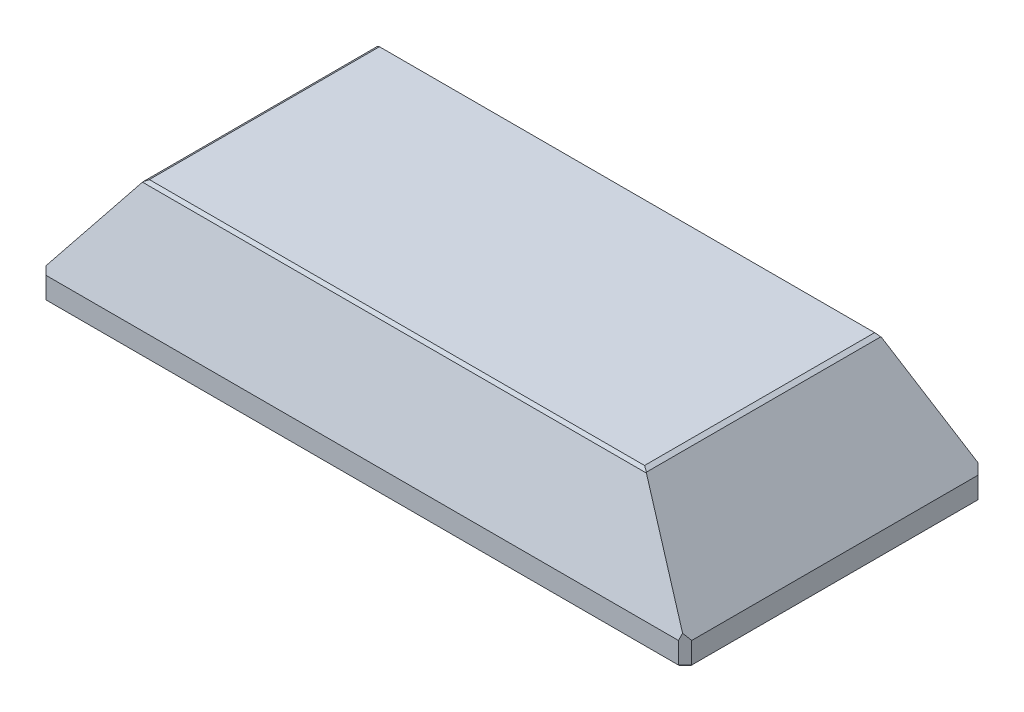
from build123d import *
from OCP.BRepFilletAPI import BRepFilletAPI_MakeChamfer

# Parameters (mm, degrees)
SKETCH1_W                       = 194
SKETCH1_H                       = 90
BOSS_EXTRUDE1_DEPTH             = 7
SKETCH3_W                       = 194
SKETCH3_H                       = 90
SKETCH2_W                       = 150
SKETCH2_H                       = 70
CHAMFER1_SIZE                   = 2
SKETCH4_R                       = 2.15
CUT_EXTRUDE1_DEPTH              = 7
SKETCH5_W                       = 150
SKETCH5_H                       = 60
CUT_EXTRUDE2_DEPTH              = 36
SKETCH6_W                       = 150
SKETCH6_H                       = 64
CUT_EXTRUDE3_DEPTH              = 32
SKETCH7_W                       = 6
SKETCH7_H                       = 64
CUT_EXTRUDE4_DEPTH              = 4
SKETCH8_R                       = 2.05
CUT_EXTRUDE5_DEPTH              = 6
CHAMFER2_SIZE                   = 1
CHAMFER2_SIZE2                  = 0.615681714
CHAMFER2_SIZE2_2                = 0.436631997
CHAMFER3_SIZE                   = 0.6
SKIZZE1_W                       = 54.050484576
SKIZZE1_H                       = 12.5
SKIZZE1_W_2                     = 40
SKIZZE1_H_2                     = 21.453027382
AUFSATZ_LINEAR_AUSTRAGEN1_DEPTH = 10
SKIZZE3_W                       = 47.974757712
SKIZZE3_H                       = 1
SCHNITT_LINEAR_AUSTRAGEN2_DEPTH = 4
SKETCH9_W                       = 150
SKETCH9_H                       = 64
CUT_EXTRUDE6_DEPTH              = 32
CHAMFER4_SIZE                   = 0.4


with BuildPart() as part:
    # Sketch1 → Boss-Extrude1 (new body)
    with BuildSketch(Plane(origin=(0, 0, 0), x_dir=(1, 0, 0), z_dir=(0, 1, 0))):
        Rectangle(SKETCH1_W, SKETCH1_H)
    extrude(amount=BOSS_EXTRUDE1_DEPTH)

    # Sketch3 → Loft2 section 0
    with BuildSketch(Plane(origin=(0, 7, 0), x_dir=(1, 0, 0), z_dir=(0, 1, 0))):
        Rectangle(SKETCH3_W, SKETCH3_H)
    # Sketch2 → Loft2 section 1
    with BuildSketch(Plane(origin=(0, 37, 0), x_dir=(1, 0, 0), z_dir=(0, 1, 0))):
        Rectangle(SKETCH2_W, SKETCH2_H)
    loft()

    # Chamfer1
    chamfer1_edges = [part.edges().sort_by_distance(p)[0] for p in [
        (-97, 3.5, 45),
        (97, 3.5, 45),
        (97, 3.5, -45),
        (-97, 3.5, -45),
    ]]
    chamfer(chamfer1_edges, length=CHAMFER1_SIZE)

    # Sketch4 → Cut-Extrude1 (cut)
    with BuildSketch(Plane.XZ):
        with Locations(Location((40, -41.5, 0), (0, 0, 270))):
            Circle(SKETCH4_R)
        with Locations(Location((-40, -41.5, 0), (0, 0, 270))):
            Circle(SKETCH4_R)
    cut_extrude1 = extrude(amount=-CUT_EXTRUDE1_DEPTH, mode=Mode.SUBTRACT)

    # Sketch5 → Cut-Extrude2 (cut)
    with BuildSketch(Plane.XZ):
        Rectangle(SKETCH5_W, SKETCH5_H)
    extrude(amount=-CUT_EXTRUDE2_DEPTH, mode=Mode.SUBTRACT)

    # Mirror1: Cut-Extrude1 across plane
    add(cut_extrude1.mirror(Plane.XY), mode=Mode.SUBTRACT)

    # Sketch6 → Cut-Extrude3 (cut)
    with BuildSketch(Plane.XZ):
        Rectangle(SKETCH6_W, SKETCH6_H)
    extrude(amount=-CUT_EXTRUDE3_DEPTH, mode=Mode.SUBTRACT)

    # Sketch7 → Cut-Extrude4 (cut)
    with BuildSketch(Plane.XZ):
        with Locations((-78, 0)):
            Rectangle(SKETCH7_W, SKETCH7_H)
        with Locations((78, 0)):
            Rectangle(SKETCH7_W, SKETCH7_H)
    extrude(amount=-CUT_EXTRUDE4_DEPTH, mode=Mode.SUBTRACT)

    # Sketch8 → Cut-Extrude5 (cut)
    with BuildSketch(Plane.XZ.offset(-4)):
        with Locations(Location((-78, 25, 0), (0, 0, 270))):
            Circle(SKETCH8_R)
        with Locations(Location((-78, -25, 0), (0, 0, 270))):
            Circle(SKETCH8_R)
        with Locations(Location((78, -25, 0), (0, 0, 90))):
            Circle(SKETCH8_R)
        with Locations(Location((78, 25, 0), (0, 0, 90))):
            Circle(SKETCH8_R)
    extrude(amount=-CUT_EXTRUDE5_DEPTH, mode=Mode.SUBTRACT)

    # Chamfer2: one chamfer whose edges measure the first distance from different faces: ONE call of the kernel's chamfer builder (chamfer() names one face for all edges)
    chamfer2_edges_1 = [part.edges().sort_by_distance(p)[0] for p in [
        (75, 37, 0),
    ]]
    chamfer2_side_1 = [part.faces().sort_by_distance(p)[0] for p in [
        (86.442553469, 21.396517997, 0),
    ]]
    chamfer2_edges_2 = [part.edges().sort_by_distance(p)[0] for p in [
        (0, 37, -35),
    ]]
    chamfer2_side_2 = [part.faces().sort_by_distance(p)[0] for p in [
        (0, 21.370454545, -40.209848485),
    ]]
    chamfer2_edges_3 = [part.edges().sort_by_distance(p)[0] for p in [
        (-75, 37, 0),
    ]]
    chamfer2_side_3 = [part.faces().sort_by_distance(p)[0] for p in [
        (-86.442553469, 21.396517997, 0),
    ]]
    chamfer2_edges_4 = [part.edges().sort_by_distance(p)[0] for p in [
        (0, 37, 35),
    ]]
    chamfer2_side_4 = [part.faces().sort_by_distance(p)[0] for p in [
        (0, 21.370454545, 40.209848485),
    ]]
    chamfer2 = BRepFilletAPI_MakeChamfer(part.part.solid().wrapped)
    for e in chamfer2_edges_1:
        chamfer2.Add(CHAMFER2_SIZE, CHAMFER2_SIZE2, e.wrapped, chamfer2_side_1[0].wrapped)  # the first distance lies on this face
    for e in chamfer2_edges_2:
        chamfer2.Add(CHAMFER2_SIZE, CHAMFER2_SIZE2_2, e.wrapped, chamfer2_side_2[0].wrapped)  # the first distance lies on this face
    for e in chamfer2_edges_3:
        chamfer2.Add(CHAMFER2_SIZE, CHAMFER2_SIZE2, e.wrapped, chamfer2_side_3[0].wrapped)  # the first distance lies on this face
    for e in chamfer2_edges_4:
        chamfer2.Add(CHAMFER2_SIZE, CHAMFER2_SIZE2_2, e.wrapped, chamfer2_side_4[0].wrapped)  # the first distance lies on this face
    add(Compound.cast(chamfer2.Shape()), mode=Mode.REPLACE)

    # Chamfer3
    chamfer3_edges = [part.edges().sort_by_distance(p)[0] for p in [
        (0, 0, 45),
        (97, 0, 0),
        (-97, 0, 0),
        (0, 0, -45),
        (-96, 0, -44),
        (96, 0, -44),
        (96, 0, 44),
        (-96, 0, 44),
    ]]
    chamfer(chamfer3_edges, length=CHAMFER3_SIZE)

    # Skizze1 → Aufsatz-Linear austragen1 (add)
    with BuildSketch(Plane.XZ.offset(-36)):
        with Locations((0, -23.75)):
            Rectangle(SKIZZE1_W, SKIZZE1_H)
        with Locations((0, 23.75)):
            Rectangle(SKIZZE1_W, SKIZZE1_H)
        with Locations((55, 0)):
            Rectangle(SKIZZE1_W_2, SKIZZE1_H_2)
    extrude(amount=AUFSATZ_LINEAR_AUSTRAGEN1_DEPTH)

    # Skizze3 → Schnitt-Linear austragen2 (cut)
    with BuildSketch(Plane(origin=(0, 36, 0), x_dir=(-1, 0, 0), z_dir=(0, -1, 0))):
        with Locations((51.012621144, -30.5)):
            Rectangle(SKIZZE3_W, SKIZZE3_H)
        with Locations((-51.012621144, -30.5)):
            Rectangle(SKIZZE3_W, SKIZZE3_H)
        with Locations((51.012621144, 30.5)):
            Rectangle(SKIZZE3_W, SKIZZE3_H)
        with Locations((-51.012621144, 30.5)):
            Rectangle(SKIZZE3_W, SKIZZE3_H)
    extrude(amount=SCHNITT_LINEAR_AUSTRAGEN2_DEPTH, mode=Mode.SUBTRACT)

    # Sketch9 → Cut-Extrude6 (cut)
    with BuildSketch(Plane.XZ.offset(-4)):
        Rectangle(SKETCH9_W, SKETCH9_H)
    extrude(amount=-CUT_EXTRUDE6_DEPTH, mode=Mode.SUBTRACT)

    # Chamfer4
    chamfer4_edges = [part.edges().sort_by_distance(p)[0] for p in [
        (40, 0, -39.35),
        (-40, 0, -39.35),
        (40, 0, 39.35),
        (-40, 0, 39.35),
    ]]
    chamfer(chamfer4_edges, length=CHAMFER4_SIZE)


solid = part.part
